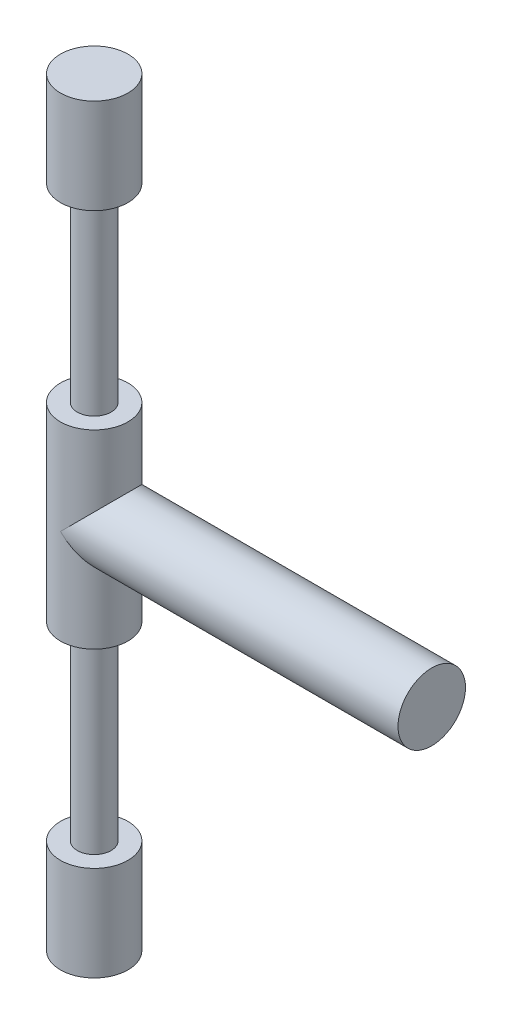
from build123d import *

# Parameters (mm, degrees)
SKETCH3_R                = 1
BOSS_EXTRUDE1_DEPTH      = 10
BOSS_EXTRUDE2_DEPTH      = 11.25
BOSS_EXTRUDE2_DEPTH_BACK = 11.25
SKETCH4_R                = 0.5
BOSS_EXTRUDE3_DEPTH      = 2.8125
BOSS_EXTRUDE3_DEPTH_BACK = 2.8125
SKETCH6_R                = 1
SKETCH7_R                = 1
BOSS_EXTRUDE4_DEPTH      = 2.8125


with BuildPart() as part:
    # Sketch3 → Boss-Extrude1 (new body)
    with BuildSketch(Plane(origin=(0, 0, 0), x_dir=(0, 0, -1), z_dir=(1, 0, 0))):
        Circle(SKETCH3_R)
    extrude(amount=-BOSS_EXTRUDE1_DEPTH)

    # Sketch4 → Boss-Extrude2 (add, two sides: drawn at the far end of the back side and taken through both)
    with BuildSketch(Plane(origin=(0, 0, 0), x_dir=(1, 0, 0), z_dir=(0, 1, 0)).offset(-BOSS_EXTRUDE2_DEPTH_BACK)):
        with Locations((-10, 0)):
            Circle(SKETCH4_R)
    extrude(amount=BOSS_EXTRUDE2_DEPTH + BOSS_EXTRUDE2_DEPTH_BACK)

    # Sketch6 → Boss-Extrude3 (add, two sides: drawn at the far end of the back side and taken through both)
    with BuildSketch(Plane(origin=(0, 0, 0), x_dir=(1, 0, 0), z_dir=(0, 1, 0)).offset(-BOSS_EXTRUDE3_DEPTH_BACK)):
        with Locations((-10, 0)):
            Circle(SKETCH6_R)
    extrude(amount=BOSS_EXTRUDE3_DEPTH + BOSS_EXTRUDE3_DEPTH_BACK)

    # Sketch7 → Boss-Extrude4 (add)
    with BuildSketch(Plane(origin=(0, 11.25, 0), x_dir=(1, 0, 0), z_dir=(0, 1, 0))):
        with Locations((-10, 0)):
            Circle(SKETCH7_R)
    boss_extrude4 = extrude(amount=-BOSS_EXTRUDE4_DEPTH)

    # Mirror1: Boss-Extrude4 across plane
    add(boss_extrude4.mirror(Plane.ZX))


solid = part.part
